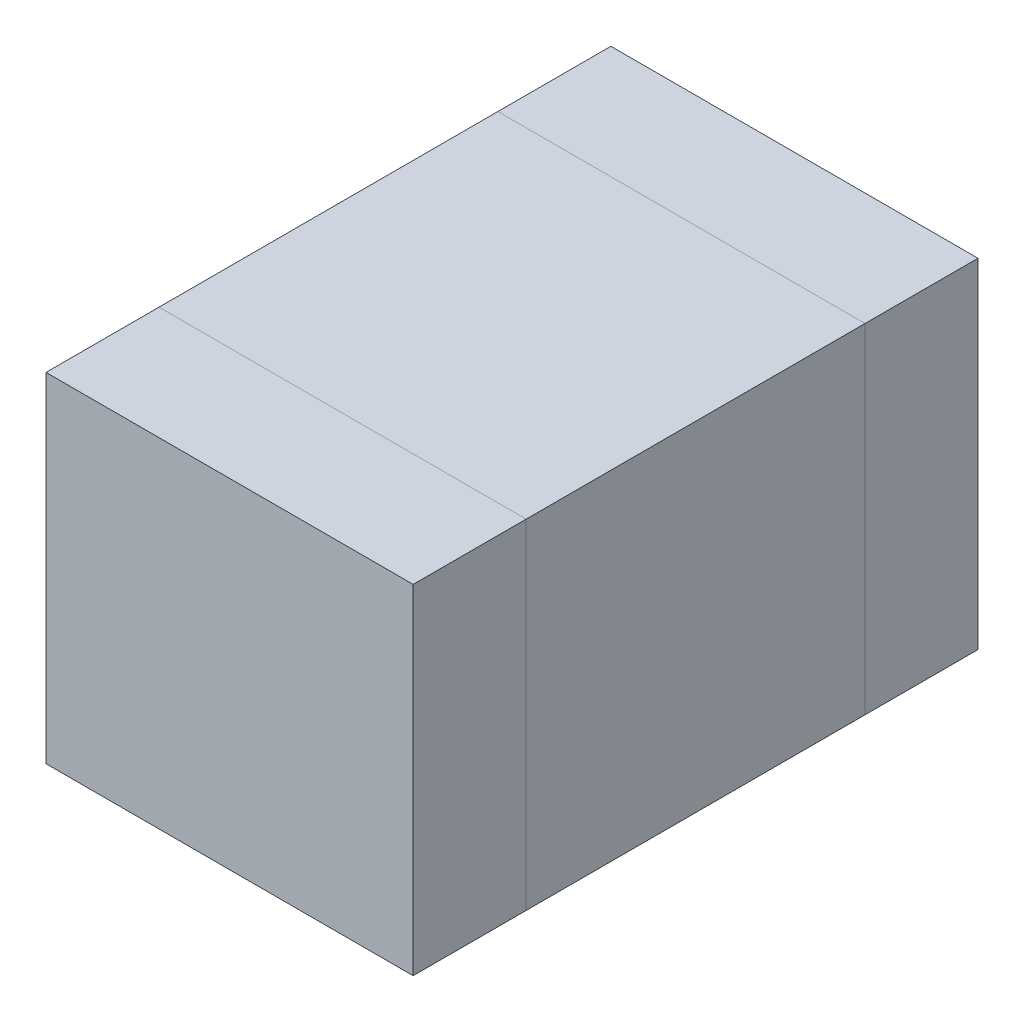
from build123d import *

# Parameters (mm, degrees)
SKETCH1_W  = 1.3
SKETCH1_H  = 1.2
MB_DEPTH   = 1.2
SKETCH2_W  = 1.3
SKETCH2_H  = 1.2
SB_L_DEPTH = 0.4
SKETCH3_W  = 1.3
SKETCH3_H  = 1.2
SB_R_DEPTH = 0.4


with BuildPart() as part:
    # Sketch1 → MB (new body)
    with BuildSketch(Plane(origin=(0, 0, 0), x_dir=(1, 0, 0), z_dir=(0, 1, 0))):
        Rectangle(SKETCH1_W, SKETCH1_H)
    extrude(amount=MB_DEPTH)


with BuildPart() as body_2:
    # Sketch2 → SB L (new body)
    with BuildSketch(Plane.XY.offset(0.6)):
        with Locations((0, 0.6)):
            Rectangle(SKETCH2_W, SKETCH2_H)
    extrude(amount=SB_L_DEPTH)


with BuildPart() as body_3:
    # Sketch3 → SB R (new body)
    with BuildSketch(Plane(origin=(0, 0, -0.6), x_dir=(-1, 0, 0), z_dir=(0, 0, -1))):
        with Locations((0, 0.6)):
            Rectangle(SKETCH3_W, SKETCH3_H)
    extrude(amount=SB_R_DEPTH)


solid = Compound([part.part, body_2.part, body_3.part])
